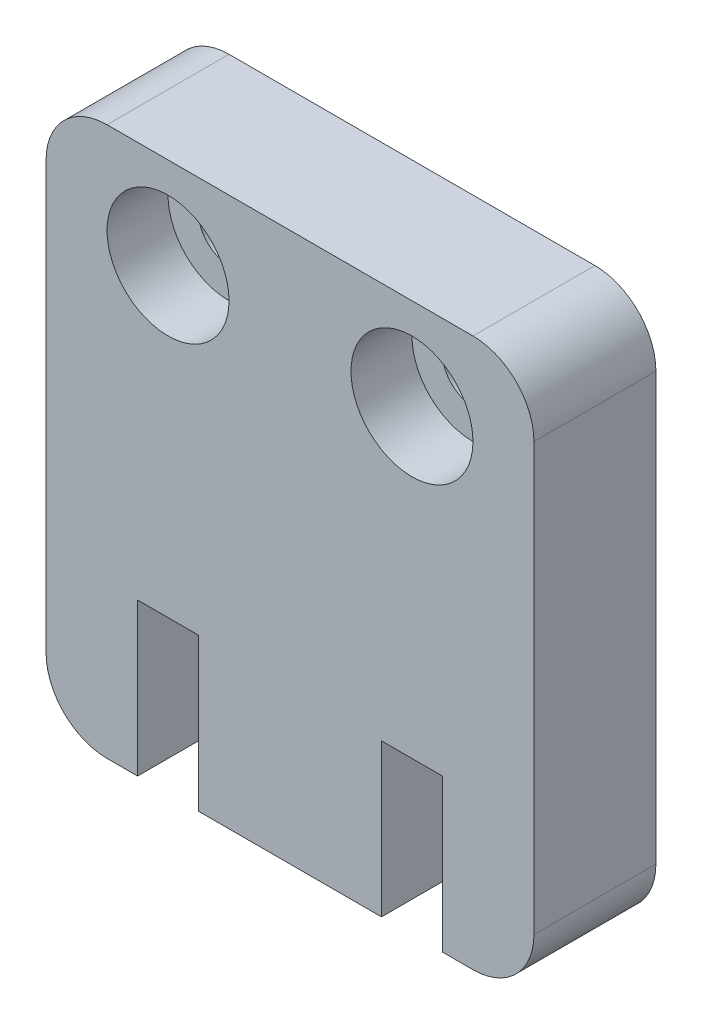
from build123d import *

# Parameters (mm, degrees)
MODEL_R             = 1
BOSS_EXTRUDE1_DEPTH = 4
SKETCH2_R           = 2
CUT_EXTRUDE1_DEPTH  = 2


with BuildPart() as part:
    # Model → Boss-Extrude1 (new body)
    with BuildSketch(Plane.XY):
        with BuildLine():
            Line((2, 0), (3, 0))
            Line((3, 0), (3, 5))
            Line((3, 5), (5, 5))
            Line((5, 5), (5, 0))
            Line((5, 0), (11, 0))
            Line((11, 0), (11, 5))
            Line((11, 5), (13, 5))
            Line((13, 5), (13, 0))
            Line((13, 0), (14, 0))
            ThreePointArc((14, 0), (15.414213562, 0.585786438), (16, 2))
            Line((16, 2), (16, 16))
            ThreePointArc((16, 16), (15.414213562, 17.414213562), (14, 18))
            Line((14, 18), (2, 18))
            ThreePointArc((2, 18), (0.585786438, 17.414213562), (0, 16))
            Line((0, 16), (0, 2))
            ThreePointArc((0, 2), (0.585786438, 0.585786438), (2, 0))
        make_face()
        with Locations((4, 15)):
            Circle(MODEL_R, mode=Mode.SUBTRACT)
        with Locations((12, 15)):
            Circle(MODEL_R, mode=Mode.SUBTRACT)
    extrude(amount=BOSS_EXTRUDE1_DEPTH)

    # Sketch2 → Cut-Extrude1 (cut)
    with BuildSketch(Plane.XY.offset(4)):
        with Locations((4, 15)):
            Circle(SKETCH2_R)
        with Locations((12, 15)):
            Circle(SKETCH2_R)
    extrude(amount=-CUT_EXTRUDE1_DEPTH, mode=Mode.SUBTRACT)


solid = part.part
